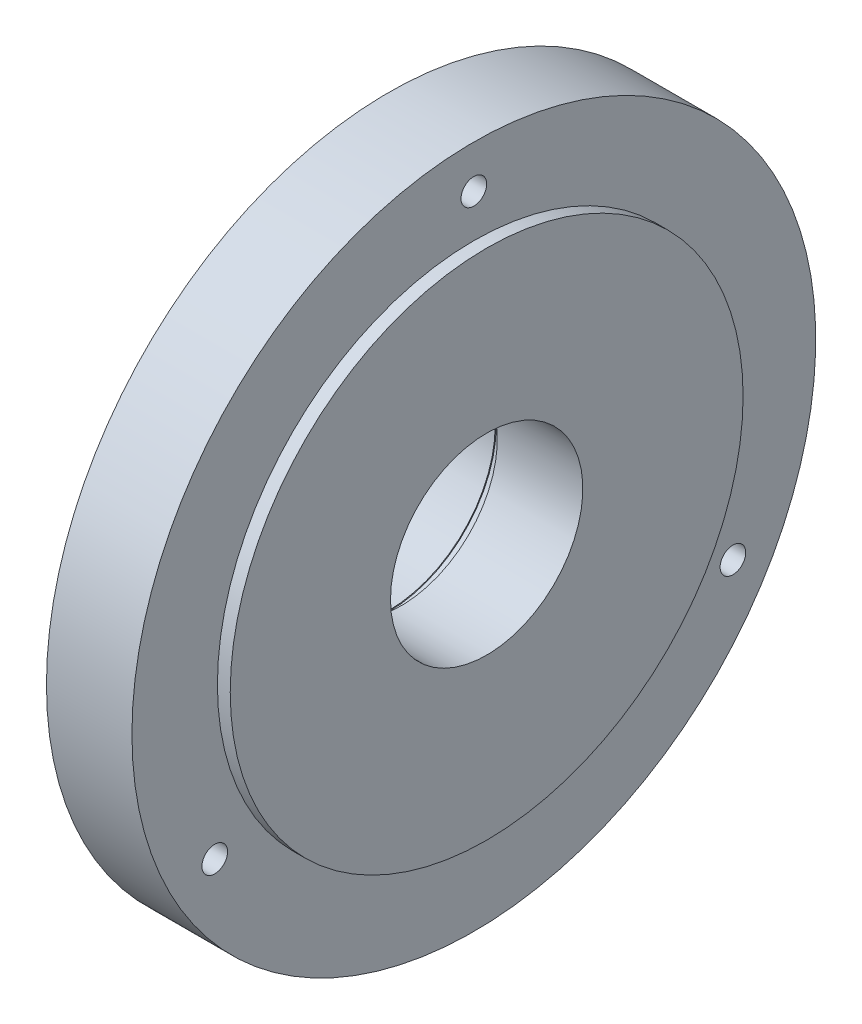
from build123d import *

# Parameters (mm, degrees)
FILLET1_R          = 6
SKETCH2_R          = 3
CUT_EXTRUDE1_DEPTH = 51


with BuildPart() as part:
    # Sketch1 → Revolve1 (revolve)
    with BuildSketch(Plane.XY):
        Polygon((0, 22.5), (-20, 22.5), (-20, 25.25), (-23, 25.25), (-23, 25), (-47, 25), (-47, 25.25), (-53, 25.25), (-53, 37.5), (-23, 37.5), (-23, 80), (-3, 80), (-3, 60), (0, 60), align=None)
    revolve(axis=Axis((-1000, 0, 0), (1, 0, 0)))

    # Fillet1
    fillet1_edges = [part.edges().sort_by_distance(p)[0] for p in [
        (-23, -37.5, 0),
    ]]
    fillet(fillet1_edges, radius=FILLET1_R)

    # Sketch2 → Cut-Extrude1 (cut, through all)
    with BuildSketch(Plane(origin=(-3, 0, 0), x_dir=(0, 0, -1), z_dir=(1, 0, 0))):
        with Locations((0, 70)):
            Circle(SKETCH2_R)
        with Locations((60.621778265, -35)):
            Circle(SKETCH2_R)
        with Locations((-60.621778265, -35)):
            Circle(SKETCH2_R)
    extrude(amount=-CUT_EXTRUDE1_DEPTH, mode=Mode.SUBTRACT)


solid = part.part
